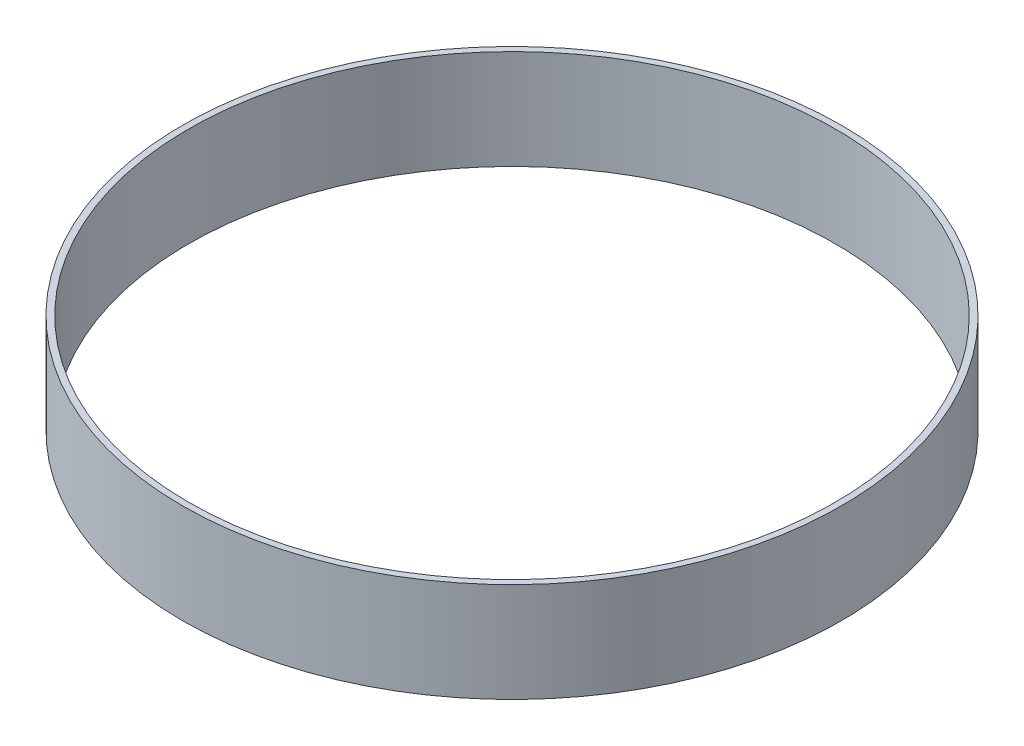
from build123d import *

# Parameters (mm, degrees)
SKETCH1_R           = 132.5
SKETCH1_R_2         = 130
BOSS_EXTRUDE1_DEPTH = 40


with BuildPart() as part:
    # Sketch1 → Boss-Extrude1 (new body)
    with BuildSketch(Plane(origin=(0, 0, 0), x_dir=(1, 0, 0), z_dir=(0, 1, 0))):
        Circle(SKETCH1_R)
        Circle(SKETCH1_R_2, mode=Mode.SUBTRACT)
    extrude(amount=BOSS_EXTRUDE1_DEPTH)


solid = part.part
